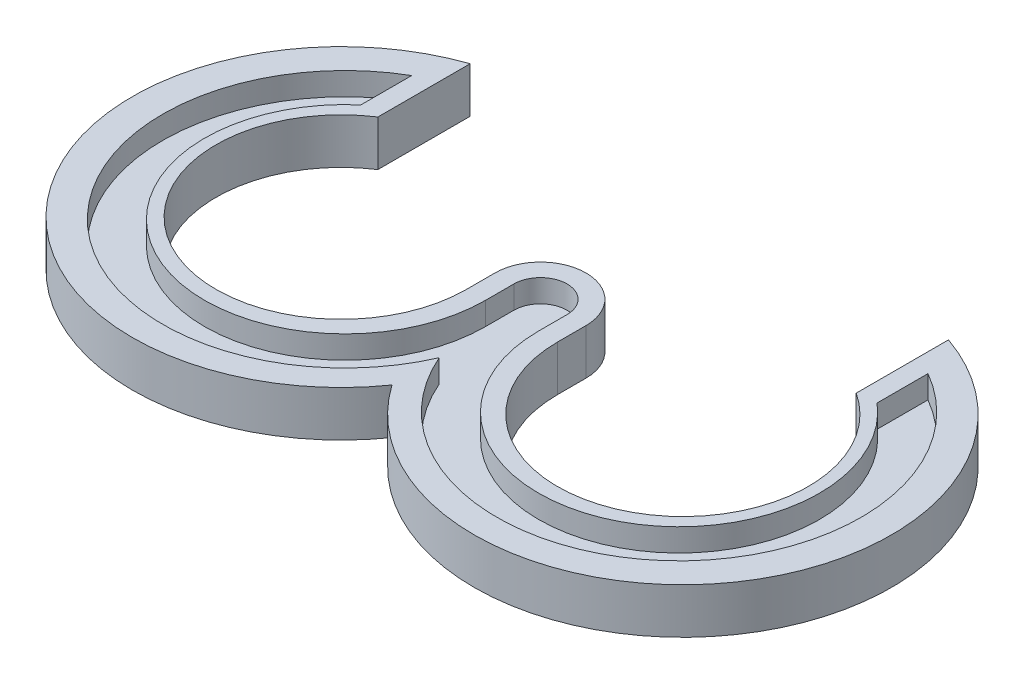
from build123d import *

# Parameters (mm, degrees)
EXTRUDE_1_DEPTH     = 6
CUT_EXTRUDE_1_DEPTH = 3


with BuildPart() as part:
    # Эскиз1 → Бобышка-Вытянуть1 (new body)
    with BuildSketch(Plane(origin=(0, 0, 0), x_dir=(1, 0, 0), z_dir=(0, 1, 0))):
        with BuildLine():
            Line((-6, -3.75), (-6, 0))
            ThreePointArc((-6, 0), (0, 6), (6, 0))
            Line((6, 0), (6, -3.75))
            ThreePointArc((6, -3.75), (30.366066361, -18.254309704), (31.5, 10.079316686))
            Line((31.5, 10.079316686), (31.5, 22.23557292))
            ThreePointArc((31.5, 22.23557292), (44.461534369, -20.301163348), (0, -19.561388301))
            ThreePointArc((0, -19.561388301), (-44.461534369, -20.301163348), (-31.5, 22.23557292))
            Line((-31.5, 22.23557292), (-31.5, 10.079316686))
            ThreePointArc((-31.5, 10.079316686), (-30.366066361, -18.254309704), (-6, -3.75))
        make_face()
    extrude(amount=EXTRUDE_1_DEPTH)

    # Эскиз4 → Вырез-Вытянуть1 (cut)
    with BuildSketch(Plane(origin=(0, 6, 0), x_dir=(1, 0, 0), z_dir=(0, 1, 0))):
        with BuildLine():
            Line((-3.5, -3.75), (-3.5, 0))
            ThreePointArc((-3.5, 0), (0, 3.5), (3.5, 0))
            Line((3.5, 0), (3.5, -3.75))
            ThreePointArc((3.5, -3.75), (29.75403121, -20.546577032), (34, 10.33012784))
            Line((34, 10.33012784), (34, 17.034609691))
            ThreePointArc((34, 17.034609691), (37.989980812, -21.647500207), (0, -13.341663047))
            ThreePointArc((0, -13.341663047), (-37.989980812, -21.647500207), (-34, 17.034609691))
            Line((-34, 17.034609691), (-34, 10.33012784))
            ThreePointArc((-34, 10.33012784), (-29.75403121, -20.546577032), (-3.5, -3.75))
        make_face()
    extrude(amount=-CUT_EXTRUDE_1_DEPTH, mode=Mode.SUBTRACT)


solid = part.part
